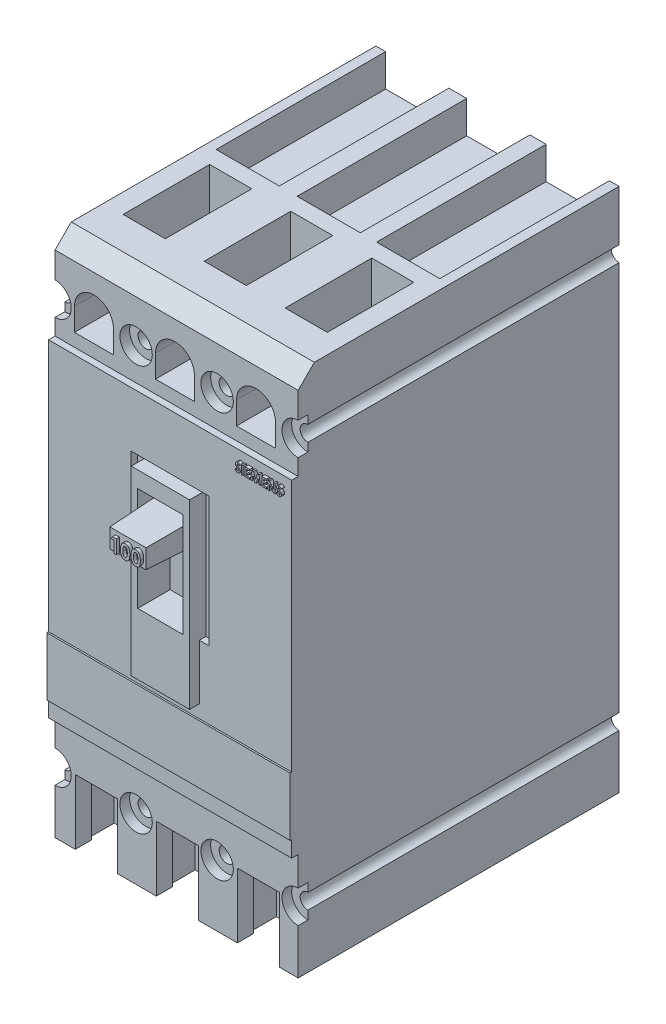
from build123d import *

# Parameters (mm, degrees)
CROQUIS1_W              = 75
CROQUIS1_H              = 162
SALIENTE_EXTRUIR1_DEPTH = 101
CROQUIS2_W              = 75
CROQUIS2_H              = 33
CROQUIS2_H_2            = 28
CORTAR_EXTRUIR1_DEPTH   = 2
CORTAR_EXTRUIR2_DEPTH   = 15
CROQUIS4_W              = 13
CROQUIS4_H              = 20
CORTAR_EXTRUIR3_DEPTH   = 5
CROQUIS5_R              = 5
CORTAR_EXTRUIR4_DEPTH   = 3
CROQUIS6_R              = 5
CORTAR_EXTRUIR5_DEPTH   = 3
CROQUIS7_R              = 2.38125
CROQUIS7_R_2            = 2.38
CORTAR_EXTRUIR6_DEPTH   = 96
CROQUIS8_R              = 5
CORTAR_EXTRUIR7_DEPTH   = 3
CROQUIS9_R              = 2.38
CORTAR_EXTRUIR8_DEPTH   = 96
CROQUIS10_W             = 13
CROQUIS10_H             = 26.695255465
CORTAR_EXTRUIR9_DEPTH   = 22
CROQUIS11_W             = 19.5
CROQUIS11_H             = 52.304744535
CORTAR_EXTRUIR10_DEPTH  = 10
CORTAR_EXTRUIR11_DEPTH  = 75
CORTAR_EXTRUIR12_DEPTH  = 20
CROQUIS14_W             = 12
CROQUIS14_H             = 13
CORTAR_EXTRUIR13_DEPTH  = 20
CORTAR_EXTRUIR14_DEPTH  = 10
CROQUIS16_W             = 24
CROQUIS16_H             = 40
CORTAR_EXTRUIR15_DEPTH  = 2
CROQUIS17_W             = 18
CROQUIS17_H             = 56
SALIENTE_EXTRUIR3_DEPTH = 5
CROQUIS18_W             = 14
CROQUIS18_H             = 32
CORTAR_EXTRUIR17_DEPTH  = 10
CROQUIS19_W             = 12.548186744
CROQUIS19_H             = 7.28259636
SALIENTE_EXTRUIR4_DEPTH = 20
SALIENTE_EXTRUIR4_TAPER = 2
SALIENTE_EXTRUIR5_DEPTH = 1
CROQUIS21_W             = 0.474893162
CROQUIS21_H             = 2.645833333
SALIENTE_EXTRUIR6_DEPTH = 1
CROQUIS22_W             = 75
CROQUIS22_H             = 18
SALIENTE_EXTRUIR7_DEPTH = 0.5


with BuildPart() as part:
    # Croquis1 → Saliente-Extruir1 (new body)
    with BuildSketch(Plane.XY):
        Rectangle(CROQUIS1_W, CROQUIS1_H)
    extrude(amount=SALIENTE_EXTRUIR1_DEPTH)

    # Croquis2 → Cortar-Extruir1 (cut)
    with BuildSketch(Plane.XY.offset(101)):
        with Locations((0, -64.5)):
            Rectangle(CROQUIS2_W, CROQUIS2_H)
        with Locations((0, 67)):
            Rectangle(CROQUIS2_W, CROQUIS2_H_2)
    extrude(amount=-CORTAR_EXTRUIR1_DEPTH, mode=Mode.SUBTRACT)

    # Croquis3 → Cortar-Extruir2 (cut)
    with BuildSketch(Plane.XY.offset(99)):
        with BuildLine():
            Line((-31.5, 57), (-19.5, 57))
            Line((-19.5, 57), (-19.5, 64))
            ThreePointArc((-19.5, 64), (-25.5, 70), (-31.5, 64))
            Line((-31.5, 64), (-31.5, 57))
        make_face()
        with BuildLine():
            Line((-6.5, 57), (-6.5, 64))
            ThreePointArc((-6.5, 64), (-0.5, 70), (5.5, 64))
            Line((5.5, 64), (5.5, 57))
            Line((5.5, 57), (-6.5, 57))
        make_face()
        with BuildLine():
            Line((18.5, 57), (18.5, 64))
            ThreePointArc((18.5, 64), (24.5, 70), (30.5, 64))
            Line((30.5, 64), (30.5, 57))
            Line((30.5, 57), (18.5, 57))
        make_face()
    extrude(amount=-CORTAR_EXTRUIR2_DEPTH, mode=Mode.SUBTRACT)

    # Croquis4 → Cortar-Extruir3 (cut)
    with BuildSketch(Plane.XY.offset(99)):
        with Locations((0.25, -71)):
            Rectangle(CROQUIS4_W, CROQUIS4_H)
        with Locations((-24.75, -71)):
            Rectangle(CROQUIS4_W, CROQUIS4_H)
        with Locations((25.25, -71)):
            Rectangle(CROQUIS4_W, CROQUIS4_H)
    extrude(amount=-CORTAR_EXTRUIR3_DEPTH, mode=Mode.SUBTRACT)

    # Croquis5 → Cortar-Extruir4 (cut)
    with BuildSketch(Plane.XY.offset(99)):
        with Locations((-12.5, 63)):
            Circle(CROQUIS5_R)
        with Locations((12.5, 63)):
            Circle(CROQUIS5_R)
    extrude(amount=-CORTAR_EXTRUIR4_DEPTH, mode=Mode.SUBTRACT)

    # Croquis6 → Cortar-Extruir5 (cut)
    with BuildSketch(Plane.XY.offset(99)):
        with Locations((-37.5, 63)):
            Circle(CROQUIS6_R)
        with Locations((37.5, 63)):
            Circle(CROQUIS6_R)
    extrude(amount=-CORTAR_EXTRUIR5_DEPTH, mode=Mode.SUBTRACT)

    # Croquis7 → Cortar-Extruir6 (cut)
    with BuildSketch(Plane.XY.offset(96)):
        with Locations((37.5, 63)):
            Circle(CROQUIS7_R)
        with Locations((12.5, 63)):
            Circle(CROQUIS7_R_2)
        with Locations((-37.5, 63)):
            Circle(CROQUIS7_R)
        with Locations((-12.5, 63)):
            Circle(CROQUIS7_R_2)
    extrude(amount=-CORTAR_EXTRUIR6_DEPTH, mode=Mode.SUBTRACT)

    # Croquis8 → Cortar-Extruir7 (cut)
    with BuildSketch(Plane.XY.offset(99)):
        with Locations((-12.5, -62)):
            Circle(CROQUIS8_R)
        with Locations((12.5, -62)):
            Circle(CROQUIS8_R)
        with Locations((37.5, -62)):
            Circle(CROQUIS8_R)
        with Locations((-37.5, -62)):
            Circle(CROQUIS8_R)
    extrude(amount=-CORTAR_EXTRUIR7_DEPTH, mode=Mode.SUBTRACT)

    # Croquis9 → Cortar-Extruir8 (cut)
    with BuildSketch(Plane.XY.offset(96)):
        with Locations((-37.5, -62)):
            Circle(CROQUIS9_R)
        with Locations((-12.5, -62)):
            Circle(CROQUIS9_R)
        with Locations((37.5, -62)):
            Circle(CROQUIS9_R)
        with Locations((12.5, -62)):
            Circle(CROQUIS9_R)
    extrude(amount=-CORTAR_EXTRUIR8_DEPTH, mode=Mode.SUBTRACT)

    # Croquis10 → Cortar-Extruir9 (cut)
    with BuildSketch(Plane(origin=(0, 81, 0), x_dir=(1, 0, 0), z_dir=(0, 1, 0))):
        with Locations((-25, -70.652372267)):
            Rectangle(CROQUIS10_W, CROQUIS10_H)
        with Locations((0, -70.652372267)):
            Rectangle(CROQUIS10_W, CROQUIS10_H)
        with Locations((25, -70.652372267)):
            Rectangle(CROQUIS10_W, CROQUIS10_H)
    extrude(amount=-CORTAR_EXTRUIR9_DEPTH, mode=Mode.SUBTRACT)

    # Croquis11 → Cortar-Extruir10 (cut)
    with BuildSketch(Plane(origin=(0, 81, 0), x_dir=(1, 0, 0), z_dir=(0, 1, 0))):
        with Locations((-24.75, -26.152372268)):
            Rectangle(CROQUIS11_W, CROQUIS11_H)
        with Locations((0.25, -26.152372268)):
            Rectangle(CROQUIS11_W, CROQUIS11_H)
        with Locations((24.75, -26.152372268)):
            Rectangle(CROQUIS11_W, CROQUIS11_H)
    extrude(amount=-CORTAR_EXTRUIR10_DEPTH, mode=Mode.SUBTRACT)

    # Croquis12 → Cortar-Extruir11 (cut)
    with BuildSketch(Plane.ZY.offset(37.5)):
        Polygon((99, 81), (94, 81), (99, 76), align=None)
    extrude(amount=-CORTAR_EXTRUIR11_DEPTH, mode=Mode.SUBTRACT)

    # Croquis13 → Cortar-Extruir12 (cut)
    with BuildSketch(Plane.XZ.offset(81)):
        Polygon((-18.25, 94), (-17.25, 94), (-17.25, 86), (-32.25, 86), (-32.25, 94), (-31.25, 94), align=None)
        Polygon((-6.25, 94), (-7.25, 94), (-7.25, 86), (7.75, 86), (7.75, 94), (6.75, 94), align=None)
        Polygon((18.75, 94), (17.75, 94), (17.75, 86), (32.75, 86), (32.75, 94), (31.75, 94), align=None)
    extrude(amount=-CORTAR_EXTRUIR12_DEPTH, mode=Mode.SUBTRACT)

    # Croquis14 → Cortar-Extruir13 (cut)
    with BuildSketch(Plane.XZ.offset(81)):
        with Locations((-24.5, 70.5)):
            Rectangle(CROQUIS14_W, CROQUIS14_H)
        with Locations((0, 70.5)):
            Rectangle(CROQUIS14_W, CROQUIS14_H)
        with Locations((24, 70.5)):
            Rectangle(CROQUIS14_W, CROQUIS14_H)
    extrude(amount=-CORTAR_EXTRUIR13_DEPTH, mode=Mode.SUBTRACT)

    # Croquis15 → Cortar-Extruir14 (cut)
    with BuildSketch(Plane.XZ.offset(81)):
        Polygon((-34.5, 59), (-15, 59), (-15, 28.610337505), (-16.610337505, 27), (-32.997400016, 27), (-34.5, 28.993221884), align=None)
        Polygon((-10, 59), (-10, 28.610337505), (-8.389662495, 27), (7.889662495, 27), (9.5, 28.610337505), (9.5, 59), align=None)
        Polygon((14.5, 59), (14.5, 28.610337505), (16.110337505, 27), (31.889662495, 27), (33.5, 28.610337505), (33.5, 59), align=None)
    extrude(amount=-CORTAR_EXTRUIR14_DEPTH, mode=Mode.SUBTRACT)

    # Croquis16 → Cortar-Extruir15 (cut)
    with BuildSketch(Plane.XY.offset(101)):
        with Locations((0, 16)):
            Rectangle(CROQUIS16_W, CROQUIS16_H)
    extrude(amount=-CORTAR_EXTRUIR15_DEPTH, mode=Mode.SUBTRACT)

    # Croquis17 → Saliente-Extruir3 (add)
    with BuildSketch(Plane.XY.offset(99)):
        with Locations((0, 7)):
            Rectangle(CROQUIS17_W, CROQUIS17_H)
    extrude(amount=SALIENTE_EXTRUIR3_DEPTH)

    # Croquis18 → Cortar-Extruir17 (cut)
    with BuildSketch(Plane.XY.offset(104)):
        with Locations((0, 14)):
            Rectangle(CROQUIS18_W, CROQUIS18_H)
    extrude(amount=-CORTAR_EXTRUIR17_DEPTH, mode=Mode.SUBTRACT)

    # Croquis19 → Saliente-Extruir4 (add)
    with BuildSketch(Plane.XY.offset(94)):
        with Locations((0, 22.535796571)):
            Rectangle(CROQUIS19_W, CROQUIS19_H)
    extrude(amount=SALIENTE_EXTRUIR4_DEPTH, taper=SALIENTE_EXTRUIR4_TAPER)

    # Croquis20 → Saliente-Extruir5 (add)
    with BuildSketch(Plane.XY.offset(114)):
        Polygon((-3.791447344, 24.246694627), (-2.616934791, 24.246694627), (-2.616934791, 20.013361294), (-3.376763851, 20.013361294), (-3.376763851, 23.541139072), (-4.245139919, 23.541139072), align=None)
        with BuildLine():
            add(Edge.make_bspline(
                [(0.111156822, 24.355241636), (0.147935703, 24.354695643), (0.220252808, 24.353622075), (0.326762291, 24.341994461), (0.429360371, 24.32442838), (0.528448425, 24.299929821), (0.623313206, 24.267506852), (0.714645161, 24.228697113), (0.801357174, 24.181464955), (0.884555101, 24.128113806), (0.964206895, 24.067712742), (1.038398179, 23.99885241), (1.108483844, 23.92311729), (1.172946794, 23.839362403), (1.23321458, 23.748349587), (1.289089173, 23.650064411), (1.340142839, 23.544025835), (1.386947768, 23.430042504), (1.428800882, 23.306405858), (1.464053709, 23.171697729), (1.494288907, 23.025887355), (1.519809547, 22.868611793), (1.539099026, 22.699661984), (1.552100523, 22.519150172), (1.561022766, 22.327424356), (1.561750937, 22.195902022), (1.562125038, 22.128331914)],
                knots=[0, 0, 0, 0, 0.000110295, 0.00021687, 0.000321015, 0.000422413, 0.000522709, 0.000621478, 0.00071975, 0.000818547, 0.00091777, 0.001019196, 0.001121821, 0.00122699, 0.001335887, 0.001449066, 0.001565884, 0.001688719, 0.001818513, 0.001957154, 0.002106175, 0.002265108, 0.002434989, 0.002616126, 0.002807967, 0.003010661, 0.003010661, 0.003010661, 0.003010661], degree=3))
            add(Edge.make_bspline(
                [(1.562125038, 22.128331914), (1.561720736, 22.059916428), (1.560935185, 21.926986366), (1.552471424, 21.733506928), (1.537896426, 21.551684492), (1.519111118, 21.381537867), (1.493380384, 21.223156907), (1.463246118, 21.07613151), (1.427436836, 20.94051497), (1.384205094, 20.816612859), (1.337683476, 20.702429349), (1.286490157, 20.596597523), (1.231517427, 20.498830731), (1.174026196, 20.407654027), (1.110864583, 20.325755255), (1.045106842, 20.250349427), (0.973889762, 20.18430885), (0.900211859, 20.124230087), (0.821374013, 20.072309979), (0.738189258, 20.026901509), (0.649174554, 19.990069846), (0.555952487, 19.958035633), (0.45693407, 19.935038525), (0.35369269, 19.916791075), (0.245062774, 19.906706415), (0.171103151, 19.905455347), (0.133205434, 19.904814285)],
                knots=[0, 0, 0, 0, 0.000205237, 0.000398773, 0.000580821, 0.000752386, 0.000912157, 0.001062008, 0.001202506, 0.001332575, 0.00145541, 0.001572228, 0.00168499, 0.001791787, 0.001895249, 0.00199497, 0.002091559, 0.002186254, 0.002279863, 0.002374345, 0.002470107, 0.002568526, 0.002669722, 0.002774702, 0.002882881, 0.002996566, 0.002996566, 0.002996566, 0.002996566], degree=3))
            add(Edge.make_bspline(
                [(0.133205434, 19.904814285), (0.095308739, 19.905467712), (0.021069671, 19.906747766), (-0.087853991, 19.916716091), (-0.191642498, 19.935112445), (-0.291444311, 19.958212188), (-0.386564823, 19.989998967), (-0.477460136, 20.027932607), (-0.563431343, 20.073057751), (-0.644716485, 20.125098828), (-0.721038031, 20.184775618), (-0.793582017, 20.251449812), (-0.862187972, 20.324952408), (-0.92581223, 20.406106696), (-0.985496771, 20.493829434), (-1.04061918, 20.589122375), (-1.09114633, 20.691846773), (-1.13865872, 20.802145817), (-1.179940972, 20.922394117), (-1.21668026, 21.053665477), (-1.246776119, 21.19705415), (-1.270981222, 21.352514073), (-1.290306562, 21.519715896), (-1.304682394, 21.698740322), (-1.313193168, 21.889670738), (-1.313970481, 22.020906724), (-1.314370688, 22.088474809)],
                knots=[0, 0, 0, 0, 0.000113686, 0.000222709, 0.000327689, 0.00042971, 0.000529737, 0.000628173, 0.0007249, 0.00082064, 0.00091733, 0.001015162, 0.001115966, 0.001218608, 0.001324217, 0.001434032, 0.001548566, 0.001667489, 0.001794074, 0.001929665, 0.002076197, 0.002233322, 0.002401517, 0.00258103, 0.002772023, 0.002974717, 0.002974717, 0.002974717, 0.002974717], degree=3))
            add(Edge.make_bspline(
                [(-1.314370688, 22.088474809), (-1.313645751, 22.182355344), (-1.312246974, 22.363499046), (-1.294520652, 22.625199028), (-1.268502908, 22.867095328), (-1.230289005, 23.088783314), (-1.183038041, 23.291084052), (-1.122530723, 23.472664893), (-1.053647542, 23.636038413), (-0.994950222, 23.73282187), (-0.966681051, 23.779433676)],
                knots=[0, 0, 0, 0, 0.00028159, 0.000543331, 0.000786536, 0.001011136, 0.001217849, 0.001409053, 0.001584881, 0.001748233, 0.001748233, 0.001748233, 0.001748233], degree=3))
            add(Edge.make_bspline(
                [(-0.966681051, 23.779433676), (-0.933811006, 23.825225101), (-0.86954359, 23.914756358), (-0.757170216, 24.032294163), (-0.636439657, 24.13281825), (-0.504872176, 24.214053668), (-0.364548567, 24.278115925), (-0.21426408, 24.323362376), (-0.054573692, 24.349725067), (0.055088362, 24.35337532), (0.111156822, 24.355241636)],
                knots=[0, 0, 0, 0, 0.000168927, 0.000330286, 0.000486315, 0.000639039, 0.00079274, 0.000947801, 0.001108545, 0.001276713, 0.001276713, 0.001276713, 0.001276713], degree=3))
        make_face()
        with BuildLine():
            add(Edge.make_bspline(
                [(0.12981334, 23.595412576), (0.096564927, 23.593836667), (0.031380389, 23.59074705), (-0.063205482, 23.564520556), (-0.152394052, 23.524012323), (-0.220237415, 23.475266997), (-0.271017498, 23.428538757), (-0.306497906, 23.386251219), (-0.340713167, 23.339061375), (-0.370933809, 23.284839789), (-0.399469984, 23.225534707), (-0.427358428, 23.160876919), (-0.450219629, 23.08927829), (-0.472680153, 23.011958155), (-0.492357668, 22.926778816), (-0.508843111, 22.833044027), (-0.523571406, 22.730144222), (-0.533844567, 22.618012001), (-0.543422236, 22.496764682), (-0.550287963, 22.366132174), (-0.553158351, 22.226149717), (-0.55407076, 22.129745877), (-0.554541628, 22.079994574)],
                knots=[0, 0, 0, 0, 9.958e-05, 0.000195231, 0.000292365, 0.00039213, 0.00044433, 0.000499059, 0.000557418, 0.000618951, 0.000684945, 0.000754874, 0.000829962, 0.00091022, 0.00099641, 0.001092056, 0.001195675, 0.001308156, 0.001429781, 0.001560553, 0.001700518, 0.00184978, 0.00184978, 0.00184978, 0.00184978], degree=3))
            add(Edge.make_bspline(
                [(-0.554541628, 22.079994574), (-0.553766636, 22.015539356), (-0.55228053, 21.891941697), (-0.544497004, 21.71420396), (-0.528895571, 21.552448307), (-0.509490538, 21.405578461), (-0.482235377, 21.274546912), (-0.45087655, 21.158113979), (-0.412151187, 21.0577639), (-0.367396569, 20.972045388), (-0.317828812, 20.899124828), (-0.264020832, 20.837142023), (-0.207804597, 20.783467838), (-0.147425416, 20.739868959), (-0.083027335, 20.706456788), (-0.01514796, 20.682423827), (0.056255845, 20.66771225), (0.105152435, 20.665672227), (0.12981334, 20.664643345)],
                knots=[0, 0, 0, 0, 0.000193379, 0.000370819, 0.000533509, 0.000680782, 0.000814998, 0.000934746, 0.001042148, 0.001136979, 0.001224243, 0.001306014, 0.001382806, 0.001456939, 0.001528626, 0.001599703, 0.001672381, 0.001746335, 0.001746335, 0.001746335, 0.001746335], degree=3))
            add(Edge.make_bspline(
                [(0.12981334, 20.664643345), (0.15362796, 20.665347383), (0.200254027, 20.6667258), (0.268245273, 20.680875071), (0.332542628, 20.703878711), (0.392951955, 20.736418976), (0.449689333, 20.777798901), (0.502477462, 20.828200328), (0.550918226, 20.888125641), (0.579140035, 20.932599086), (0.593682196, 20.955515407)],
                knots=[0, 0, 0, 0, 7.136e-05, 0.000139714, 0.000207312, 0.000275603, 0.000344809, 0.000417388, 0.000493941, 0.00057532, 0.00057532, 0.00057532, 0.00057532], degree=3))
            add(Edge.make_bspline(
                [(0.593682196, 20.955515407), (0.610803143, 20.986829828), (0.646704379, 21.052493627), (0.688249351, 21.163298841), (0.723219593, 21.288268809), (0.753317969, 21.427792449), (0.773903423, 21.58242006), (0.79163159, 21.751171134), (0.800182325, 21.934895434), (0.801573149, 22.062180291), (0.802295978, 22.128331914)],
                knots=[0, 0, 0, 0, 0.000106959, 0.000224283, 0.000353931, 0.000496139, 0.000652046, 0.000821653, 0.001005064, 0.00120353, 0.00120353, 0.00120353, 0.00120353], degree=3))
            add(Edge.make_bspline(
                [(0.802295978, 22.128331914), (0.802016765, 22.195057764), (0.801479327, 22.323493635), (0.791618893, 22.507878437), (0.777887486, 22.676283352), (0.757802402, 22.8283324), (0.73195929, 22.964394691), (0.700107557, 23.084461329), (0.662556733, 23.188768943), (0.618025931, 23.277213524), (0.568705301, 23.352379285), (0.516349946, 23.416865677), (0.460738488, 23.471922533), (0.401963926, 23.517757039), (0.338665902, 23.552778039), (0.272053492, 23.577505762), (0.201990134, 23.592465206), (0.154197006, 23.594416859), (0.12981334, 23.595412576)],
                knots=[0, 0, 0, 0, 0.00020015, 0.000385254, 0.00055378, 0.000706935, 0.000845142, 0.00096898, 0.001079252, 0.001177099, 0.001265301, 0.001348477, 0.001425833, 0.001499616, 0.001571358, 0.001641928, 0.001712114, 0.001785221, 0.001785221, 0.001785221, 0.001785221], degree=3))
        make_face(mode=Mode.SUBTRACT)
        with BuildLine():
            add(Edge.make_bspline(
                [(3.367567079, 24.355241636), (3.404345959, 24.354695643), (3.476663064, 24.353622075), (3.583172547, 24.341994461), (3.685770627, 24.32442838), (3.784858681, 24.299929821), (3.879723463, 24.267506852), (3.971055417, 24.228697113), (4.057767431, 24.181464955), (4.140965358, 24.128113806), (4.220617151, 24.067712742), (4.294808435, 23.99885241), (4.3648941, 23.92311729), (4.42935705, 23.839362403), (4.489624837, 23.748349587), (4.54549943, 23.650064411), (4.596553096, 23.544025835), (4.643358024, 23.430042504), (4.685211139, 23.306405858), (4.720463965, 23.171697729), (4.750699163, 23.025887355), (4.776219803, 22.868611793), (4.795509282, 22.699661984), (4.80851078, 22.519150172), (4.817433023, 22.327424356), (4.818161194, 22.195902022), (4.818535295, 22.128331914)],
                knots=[0, 0, 0, 0, 0.000110295, 0.00021687, 0.000321015, 0.000422413, 0.000522709, 0.000621478, 0.00071975, 0.000818547, 0.00091777, 0.001019196, 0.001121821, 0.00122699, 0.001335887, 0.001449066, 0.001565884, 0.001688719, 0.001818513, 0.001957154, 0.002106175, 0.002265108, 0.002434989, 0.002616126, 0.002807967, 0.003010661, 0.003010661, 0.003010661, 0.003010661], degree=3))
            add(Edge.make_bspline(
                [(4.818535295, 22.128331914), (4.818130993, 22.059916428), (4.817345442, 21.926986366), (4.80888168, 21.733506928), (4.794306683, 21.551684492), (4.775521375, 21.381537867), (4.749790641, 21.223156907), (4.719656375, 21.07613151), (4.683847093, 20.94051497), (4.64061535, 20.816612859), (4.594093733, 20.702429349), (4.542900413, 20.596597523), (4.487927684, 20.498830731), (4.430436453, 20.407654027), (4.36727484, 20.325755255), (4.301517098, 20.250349427), (4.230300019, 20.18430885), (4.156622116, 20.124230087), (4.077784269, 20.072309979), (3.994599514, 20.026901509), (3.90558481, 19.990069846), (3.812362744, 19.958035633), (3.713344326, 19.935038525), (3.610102946, 19.916791075), (3.50147303, 19.906706415), (3.427513408, 19.905455347), (3.38961569, 19.904814285)],
                knots=[0, 0, 0, 0, 0.000205237, 0.000398773, 0.000580821, 0.000752386, 0.000912157, 0.001062008, 0.001202506, 0.001332575, 0.00145541, 0.001572228, 0.00168499, 0.001791787, 0.001895249, 0.00199497, 0.002091559, 0.002186254, 0.002279863, 0.002374345, 0.002470107, 0.002568526, 0.002669722, 0.002774702, 0.002882881, 0.002996566, 0.002996566, 0.002996566, 0.002996566], degree=3))
            add(Edge.make_bspline(
                [(3.38961569, 19.904814285), (3.351718995, 19.905467712), (3.277479928, 19.906747766), (3.168556265, 19.916716091), (3.064767758, 19.935112445), (2.964965946, 19.958212188), (2.869845433, 19.989998967), (2.77895012, 20.027932607), (2.692978913, 20.073057751), (2.611693771, 20.125098828), (2.535372226, 20.184775618), (2.462828239, 20.251449812), (2.394222284, 20.324952408), (2.330598027, 20.406106696), (2.270913486, 20.493829434), (2.215791076, 20.589122375), (2.165263926, 20.691846773), (2.117751537, 20.802145817), (2.076469284, 20.922394117), (2.039729996, 21.053665477), (2.009634138, 21.19705415), (1.985429035, 21.352514073), (1.966103694, 21.519715896), (1.951727862, 21.698740322), (1.943217088, 21.889670738), (1.942439775, 22.020906724), (1.942039568, 22.088474809)],
                knots=[0, 0, 0, 0, 0.000113686, 0.000222709, 0.000327689, 0.00042971, 0.000529737, 0.000628173, 0.0007249, 0.00082064, 0.00091733, 0.001015162, 0.001115966, 0.001218608, 0.001324217, 0.001434032, 0.001548566, 0.001667489, 0.001794074, 0.001929665, 0.002076197, 0.002233322, 0.002401517, 0.00258103, 0.002772023, 0.002974717, 0.002974717, 0.002974717, 0.002974717], degree=3))
            add(Edge.make_bspline(
                [(1.942039568, 22.088474809), (1.942764506, 22.182355344), (1.944163282, 22.363499046), (1.961889604, 22.625199028), (1.987907348, 22.867095328), (2.026121252, 23.088783314), (2.073372215, 23.291084052), (2.133879534, 23.472664893), (2.202762714, 23.636038413), (2.261460034, 23.73282187), (2.289729205, 23.779433676)],
                knots=[0, 0, 0, 0, 0.00028159, 0.000543331, 0.000786536, 0.001011136, 0.001217849, 0.001409053, 0.001584881, 0.001748233, 0.001748233, 0.001748233, 0.001748233], degree=3))
            add(Edge.make_bspline(
                [(2.289729205, 23.779433676), (2.322599251, 23.825225101), (2.386866667, 23.914756358), (2.49924004, 24.032294163), (2.619970599, 24.13281825), (2.75153808, 24.214053668), (2.89186169, 24.278115925), (3.042146176, 24.323362376), (3.201836565, 24.349725067), (3.311498618, 24.35337532), (3.367567079, 24.355241636)],
                knots=[0, 0, 0, 0, 0.000168927, 0.000330286, 0.000486315, 0.000639039, 0.00079274, 0.000947801, 0.001108545, 0.001276713, 0.001276713, 0.001276713, 0.001276713], degree=3))
        make_face()
        with BuildLine():
            add(Edge.make_bspline(
                [(3.386223596, 23.595412576), (3.352975183, 23.593836667), (3.287790645, 23.59074705), (3.193204775, 23.564520556), (3.104016204, 23.524012323), (3.036172841, 23.475266997), (2.985392758, 23.428538757), (2.94991235, 23.386251219), (2.915697089, 23.339061375), (2.885476447, 23.284839789), (2.856940273, 23.225534707), (2.829051828, 23.160876919), (2.806190627, 23.08927829), (2.783730104, 23.011958155), (2.764052589, 22.926778816), (2.747567145, 22.833044027), (2.732838851, 22.730144222), (2.72256569, 22.618012001), (2.71298802, 22.496764682), (2.706122294, 22.366132174), (2.703251906, 22.226149717), (2.702339497, 22.129745877), (2.701868628, 22.079994574)],
                knots=[0, 0, 0, 0, 9.958e-05, 0.000195231, 0.000292365, 0.00039213, 0.00044433, 0.000499059, 0.000557418, 0.000618951, 0.000684945, 0.000754874, 0.000829962, 0.00091022, 0.00099641, 0.001092056, 0.001195675, 0.001308156, 0.001429781, 0.001560553, 0.001700518, 0.00184978, 0.00184978, 0.00184978, 0.00184978], degree=3))
            add(Edge.make_bspline(
                [(2.701868628, 22.079994574), (2.702643621, 22.015539356), (2.704129726, 21.891941697), (2.711913253, 21.71420396), (2.727514686, 21.552448307), (2.746919719, 21.405578461), (2.774174879, 21.274546912), (2.805533706, 21.158113979), (2.844259069, 21.0577639), (2.889013688, 20.972045388), (2.938581444, 20.899124828), (2.992389424, 20.837142023), (3.048605659, 20.783467838), (3.10898484, 20.739868959), (3.173382921, 20.706456788), (3.241262296, 20.682423827), (3.312666101, 20.66771225), (3.361562691, 20.665672227), (3.386223596, 20.664643345)],
                knots=[0, 0, 0, 0, 0.000193379, 0.000370819, 0.000533509, 0.000680782, 0.000814998, 0.000934746, 0.001042148, 0.001136979, 0.001224243, 0.001306014, 0.001382806, 0.001456939, 0.001528626, 0.001599703, 0.001672381, 0.001746335, 0.001746335, 0.001746335, 0.001746335], degree=3))
            add(Edge.make_bspline(
                [(3.386223596, 20.664643345), (3.410038217, 20.665347383), (3.456664283, 20.6667258), (3.52465553, 20.680875071), (3.588952884, 20.703878711), (3.649362212, 20.736418976), (3.706099589, 20.777798901), (3.758887718, 20.828200328), (3.807328482, 20.888125641), (3.835550291, 20.932599086), (3.850092453, 20.955515407)],
                knots=[0, 0, 0, 0, 7.136e-05, 0.000139714, 0.000207312, 0.000275603, 0.000344809, 0.000417388, 0.000493941, 0.00057532, 0.00057532, 0.00057532, 0.00057532], degree=3))
            add(Edge.make_bspline(
                [(3.850092453, 20.955515407), (3.867213399, 20.986829828), (3.903114635, 21.052493627), (3.944659608, 21.163298841), (3.97962985, 21.288268809), (4.009728226, 21.427792449), (4.030313679, 21.58242006), (4.048041846, 21.751171134), (4.056592582, 21.934895434), (4.057983405, 22.062180291), (4.058706235, 22.128331914)],
                knots=[0, 0, 0, 0, 0.000106959, 0.000224283, 0.000353931, 0.000496139, 0.000652046, 0.000821653, 0.001005064, 0.00120353, 0.00120353, 0.00120353, 0.00120353], degree=3))
            add(Edge.make_bspline(
                [(4.058706235, 22.128331914), (4.058427021, 22.195057764), (4.057889583, 22.323493635), (4.04802915, 22.507878437), (4.034297743, 22.676283352), (4.014212658, 22.8283324), (3.988369546, 22.964394691), (3.956517813, 23.084461329), (3.918966989, 23.188768943), (3.874436187, 23.277213524), (3.825115557, 23.352379285), (3.772760203, 23.416865677), (3.717148744, 23.471922533), (3.658374182, 23.517757039), (3.595076159, 23.552778039), (3.528463748, 23.577505762), (3.458400391, 23.592465206), (3.410607262, 23.594416859), (3.386223596, 23.595412576)],
                knots=[0, 0, 0, 0, 0.00020015, 0.000385254, 0.00055378, 0.000706935, 0.000845142, 0.00096898, 0.001079252, 0.001177099, 0.001265301, 0.001348477, 0.001425833, 0.001499616, 0.001571358, 0.001641928, 0.001712114, 0.001785221, 0.001785221, 0.001785221, 0.001785221], degree=3))
        make_face(mode=Mode.SUBTRACT)
    extrude(amount=SALIENTE_EXTRUIR5_DEPTH)

    # Croquis21 → Saliente-Extruir6 (add)
    with BuildSketch(Plane.XY.offset(101)):
        with BuildLine():
            Line((22.56777865, 50.042662848), (22.212668808, 49.717763842))
            add(Edge.make_bspline(
                [(22.212668808, 49.717763842), (22.197457425, 49.73922108), (22.168253691, 49.780415982), (22.120917484, 49.835576928), (22.073795025, 49.88263332), (22.026449751, 49.921388578), (21.978462014, 49.951607235), (21.929915112, 49.973002378), (21.881084272, 49.986603474), (21.848277485, 49.988297137), (21.83211826, 49.989131364)],
                knots=[0, 0, 0, 0, 7.8871e-05, 0.000151421, 0.000217757, 0.000278432, 0.000334614, 0.000387299, 0.000437179, 0.000485597, 0.000485597, 0.000485597, 0.000485597], degree=3))
            add(Edge.make_bspline(
                [(21.83211826, 49.989131364), (21.817045399, 49.98860276), (21.787943665, 49.987582164), (21.746456984, 49.977437518), (21.709624518, 49.959929349), (21.677482213, 49.937035946), (21.652020765, 49.909454702), (21.631691774, 49.880529069), (21.620244844, 49.848601711), (21.618738202, 49.826672714), (21.617992325, 49.81581656)],
                knots=[0, 0, 0, 0, 4.5163e-05, 8.7199e-05, 0.000127031, 0.000166895, 0.000204764, 0.000239162, 0.000272355, 0.000304898, 0.000304898, 0.000304898, 0.000304898], degree=3))
            add(Edge.make_bspline(
                [(21.617992325, 49.81581656), (21.618459729, 49.804803855), (21.619401014, 49.782625798), (21.628492546, 49.750121093), (21.642196081, 49.718360213), (21.655290368, 49.699025853), (21.661983545, 49.689143049)],
                knots=[0, 0, 0, 0, 3.2968e-05, 6.6392e-05, 0.000100565, 0.000136297, 0.000136297, 0.000136297, 0.000136297], degree=3))
            add(Edge.make_bspline(
                [(21.661983545, 49.689143049), (21.668068366, 49.681461249), (21.682074822, 49.663778759), (21.708782263, 49.635772451), (21.742321201, 49.601462273), (21.783982284, 49.56202805), (21.832036045, 49.516051575), (21.88870984, 49.465340199), (21.952372348, 49.40832345), (21.997622184, 49.368619051), (22.021333505, 49.347813589)],
                knots=[0, 0, 0, 0, 2.9386e-05, 6.7643e-05, 0.00011599, 0.000173342, 0.000239704, 0.000315502, 0.000401464, 0.000496098, 0.000496098, 0.000496098, 0.000496098], degree=3))
            add(Edge.make_bspline(
                [(22.021333505, 49.347813589), (22.04358999, 49.328551723), (22.085828177, 49.291996703), (22.145924728, 49.240112722), (22.198739587, 49.19343397), (22.245042147, 49.152660994), (22.284130505, 49.117365993), (22.31616899, 49.087380256), (22.341548896, 49.063287552), (22.355975887, 49.048735544), (22.36213295, 49.042525127)],
                knots=[0, 0, 0, 0, 8.8303e-05, 0.00016758, 0.000238182, 0.000299759, 0.000352668, 0.000396168, 0.000431405, 0.000457639, 0.000457639, 0.000457639, 0.000457639], degree=3))
            add(Edge.make_bspline(
                [(22.36213295, 49.042525127), (22.385491565, 49.017246104), (22.430395025, 48.968650943), (22.488753694, 48.893343726), (22.536784766, 48.819828528), (22.573942514, 48.746722039), (22.60200554, 48.672969479), (22.621790345, 48.596762071), (22.633639596, 48.517303495), (22.63495514, 48.463082716), (22.635620531, 48.435658307)],
                knots=[0, 0, 0, 0, 0.000103217, 0.000198419, 0.000285453, 0.000366281, 0.000443948, 0.000521723, 0.000602076, 0.000684312, 0.000684312, 0.000684312, 0.000684312], degree=3))
            add(Edge.make_bspline(
                [(22.635620531, 48.435658307), (22.635146923, 48.408936584), (22.634217686, 48.356507568), (22.622836318, 48.279785513), (22.606607156, 48.206359177), (22.581514023, 48.137027541), (22.550930662, 48.070652549), (22.512590002, 48.008268111), (22.467564154, 47.949242872), (22.415957619, 47.89463198), (22.358874663, 47.845076381), (22.297647767, 47.800960816), (22.231678225, 47.764537798), (22.161529669, 47.73454604), (22.087239649, 47.711445988), (22.008896666, 47.694372896), (21.92638089, 47.684125895), (21.869955413, 47.683054693), (21.84112851, 47.682507432)],
                knots=[0, 0, 0, 0, 8.0095e-05, 0.00015715, 0.000232233, 0.000305321, 0.000377877, 0.000451142, 0.000524499, 0.000600237, 0.000676123, 0.000750983, 0.000826195, 0.000901705, 0.000979485, 0.001059222, 0.001141989, 0.00122844, 0.00122844, 0.00122844, 0.00122844], degree=3))
            add(Edge.make_bspline(
                [(21.84112851, 47.682507432), (21.818499637, 47.682908883), (21.77368149, 47.683703987), (21.707626316, 47.690195348), (21.64384258, 47.700671713), (21.582402126, 47.715687474), (21.523028155, 47.73471448), (21.465718229, 47.757955239), (21.410867977, 47.785769974), (21.358062375, 47.817586703), (21.307558126, 47.854530117), (21.258716621, 47.895844919), (21.212023001, 47.94216655), (21.167253006, 47.99338546), (21.124693088, 48.04964669), (21.082950106, 48.110166697), (21.043879246, 48.176068651), (21.019743438, 48.222299405), (21.007415402, 48.245913048)],
                knots=[0, 0, 0, 0, 6.7875e-05, 0.000134431, 0.00019891, 0.000261643, 0.000323996, 0.000385805, 0.00044696, 0.000508315, 0.000570547, 0.000634474, 0.000700061, 0.000767671, 0.000838378, 0.000911589, 0.000988124, 0.001068032, 0.001068032, 0.001068032, 0.001068032], degree=3))
            Line((21.007415402, 48.245913048), (21.425066978, 48.496609996))
            add(Edge.make_bspline(
                [(21.425066978, 48.496609996), (21.440487508, 48.469805426), (21.470049981, 48.418418775), (21.520146355, 48.349374296), (21.571467532, 48.290249128), (21.625200014, 48.242088314), (21.680690431, 48.20424788), (21.738206817, 48.177204481), (21.79778958, 48.160464648), (21.838374652, 48.158420327), (21.858618995, 48.157400595)],
                knots=[0, 0, 0, 0, 9.2715e-05, 0.000177742, 0.000255474, 0.000327175, 0.000393619, 0.000456217, 0.00051716, 0.000577813, 0.000577813, 0.000577813, 0.000577813], degree=3))
            add(Edge.make_bspline(
                [(21.858618995, 48.157400595), (21.87921039, 48.158233364), (21.919160696, 48.159849057), (21.976184645, 48.174772726), (22.02846636, 48.198203982), (22.073658289, 48.231637153), (22.111923965, 48.270224114), (22.14016623, 48.313153873), (22.157908212, 48.359602835), (22.15978397, 48.39186934), (22.160727368, 48.408097543)],
                knots=[0, 0, 0, 0, 6.1666e-05, 0.000119642, 0.000175613, 0.000232545, 0.000287267, 0.000337839, 0.000385792, 0.000434314, 0.000434314, 0.000434314, 0.000434314], degree=3))
            add(Edge.make_bspline(
                [(22.160727368, 48.408097543), (22.159856178, 48.423195245), (22.158086439, 48.453864781), (22.145051087, 48.49946545), (22.124672855, 48.545045381), (22.10056397, 48.582431273), (22.07603016, 48.613733467), (22.052570304, 48.640855402), (22.024002406, 48.670820392), (21.990398901, 48.703666131), (21.952203778, 48.739681768), (21.909384865, 48.778863776), (21.861451837, 48.820867009), (21.827572679, 48.849479196), (21.809857643, 48.864440191)],
                knots=[0, 0, 0, 0, 4.525e-05, 9.1922e-05, 0.00014127, 0.000194644, 0.000224859, 0.00026056, 0.000302175, 0.000349024, 0.000401514, 0.000459664, 0.000523135, 0.000592696, 0.000592696, 0.000592696, 0.000592696], degree=3))
            add(Edge.make_bspline(
                [(21.809857643, 48.864440191), (21.776180655, 48.892934152), (21.711544322, 48.947622688), (21.620204983, 49.028395934), (21.53790006, 49.103885934), (21.465340427, 49.175025908), (21.401601562, 49.240502067), (21.347115131, 49.300846233), (21.302479695, 49.356523879), (21.255510522, 49.422470324), (21.210880418, 49.502830599), (21.172307342, 49.599513326), (21.147282759, 49.696183785), (21.144479102, 49.761083007), (21.143099163, 49.793025928)],
                knots=[0, 0, 0, 0, 0.000132338, 0.000253997, 0.000365771, 0.000467342, 0.0005588, 0.000639876, 0.000711145, 0.000772759, 0.000882617, 0.000985861, 0.001084587, 0.001180278, 0.001180278, 0.001180278, 0.001180278], degree=3))
            add(Edge.make_bspline(
                [(21.143099163, 49.793025928), (21.143673078, 49.815678134), (21.144803752, 49.860305412), (21.154889538, 49.925923323), (21.16996313, 49.989239093), (21.191854312, 50.050021718), (21.220266424, 50.108195065), (21.25477183, 50.164043918), (21.295906334, 50.217054255), (21.342262143, 50.267190936), (21.393334376, 50.313010156), (21.447911547, 50.353450209), (21.505684745, 50.387606466), (21.566300543, 50.415941561), (21.630134551, 50.437630277), (21.696716507, 50.453004319), (21.766141911, 50.46214831), (21.813363572, 50.463391329), (21.837418407, 50.464024526)],
                knots=[0, 0, 0, 0, 6.7916e-05, 0.000133803, 0.00019872, 0.000262931, 0.00032717, 0.000392622, 0.000459515, 0.000528149, 0.00059721, 0.000665054, 0.000731591, 0.000798224, 0.000865435, 0.000933447, 0.001002935, 0.001075087, 0.001075087, 0.001075087, 0.001075087], degree=3))
            add(Edge.make_bspline(
                [(21.837418407, 50.464024526), (21.868592283, 50.462884119), (21.930693958, 50.460612308), (22.022513076, 50.442847483), (22.112198152, 50.414910426), (22.184468067, 50.38120744), (22.241971889, 50.348559341), (22.286043198, 50.318501084), (22.330888126, 50.284067736), (22.376868321, 50.245150787), (22.423129399, 50.201016991), (22.470986784, 50.152716987), (22.519788362, 50.099833352), (22.551501649, 50.062053529), (22.56777865, 50.042662848)],
                knots=[0, 0, 0, 0, 9.3465e-05, 0.000186191, 0.00027956, 0.000374659, 0.000424753, 0.00047782, 0.000534534, 0.000594323, 0.000658437, 0.000726273, 0.000798292, 0.000874234, 0.000874234, 0.000874234, 0.000874234], degree=3))
        make_face()
        with Locations((23.280118394, 49.07326598)):
            Rectangle(CROQUIS21_W, CROQUIS21_H)
        Polygon((24.128141898, 50.396182646), (25.552821385, 50.396182646), (25.552821385, 49.921289483), (24.603035061, 49.921289483), (24.603035061, 49.412475381), (25.552821385, 49.412475381), (25.552821385, 48.937582219), (24.603035061, 48.937582219), (24.603035061, 48.225242475), (25.552821385, 48.225242475), (25.552821385, 47.750349313), (24.128141898, 47.750349313), align=None)
        Polygon((26.23707035, 50.396182646), (26.729984012, 50.396182646), (27.333670744, 48.550671495), (27.941597594, 50.396182646), (28.429741124, 50.396182646), (28.877073522, 47.750349313), (28.396350198, 47.750349313), (28.113852368, 49.421485631), (27.56369712, 47.750349313), (27.100464281, 47.750349313), (26.55348912, 49.421485631), (26.271521305, 47.750349313), (25.790267967, 47.750349313), align=None)
        Polygon((29.318045744, 50.396182646), (30.742725231, 50.396182646), (30.742725231, 49.921289483), (29.792938907, 49.921289483), (29.792938907, 49.412475381), (30.742725231, 49.412475381), (30.742725231, 48.937582219), (29.792938907, 48.937582219), (29.792938907, 48.225242475), (30.742725231, 48.225242475), (30.742725231, 47.750349313), (29.318045744, 47.750349313), align=None)
        Polygon((31.217618394, 50.396182646), (31.645340249, 50.396182646), (32.845823522, 48.655084389), (32.845823522, 50.396182646), (33.320716684, 50.396182646), (33.320716684, 47.750349313), (32.889814741, 47.750349313), (31.692511556, 49.486147423), (31.692511556, 47.750349313), (31.217618394, 47.750349313), align=None)
        with BuildLine():
            Line((35.288131214, 50.042662848), (34.933021372, 49.717763842))
            add(Edge.make_bspline(
                [(34.933021372, 49.717763842), (34.917809989, 49.73922108), (34.888606255, 49.780415982), (34.841270048, 49.835576928), (34.794147589, 49.88263332), (34.746802315, 49.921388578), (34.698814578, 49.951607235), (34.650267676, 49.973002378), (34.601436836, 49.986603474), (34.568630049, 49.988297137), (34.552470824, 49.989131364)],
                knots=[0, 0, 0, 0, 7.8871e-05, 0.000151421, 0.000217757, 0.000278432, 0.000334614, 0.000387299, 0.000437179, 0.000485597, 0.000485597, 0.000485597, 0.000485597], degree=3))
            add(Edge.make_bspline(
                [(34.552470824, 49.989131364), (34.537397964, 49.98860276), (34.508296229, 49.987582164), (34.466809548, 49.977437518), (34.429977082, 49.959929349), (34.397834777, 49.937035946), (34.372373329, 49.909454702), (34.352044338, 49.880529069), (34.340597408, 49.848601711), (34.339090766, 49.826672714), (34.33834489, 49.81581656)],
                knots=[0, 0, 0, 0, 4.5163e-05, 8.7199e-05, 0.000127031, 0.000166895, 0.000204764, 0.000239162, 0.000272355, 0.000304898, 0.000304898, 0.000304898, 0.000304898], degree=3))
            add(Edge.make_bspline(
                [(34.33834489, 49.81581656), (34.338812293, 49.804803855), (34.339753578, 49.782625798), (34.34884511, 49.750121093), (34.362548645, 49.718360213), (34.375642932, 49.699025853), (34.382336109, 49.689143049)],
                knots=[0, 0, 0, 0, 3.2968e-05, 6.6392e-05, 0.000100565, 0.000136297, 0.000136297, 0.000136297, 0.000136297], degree=3))
            add(Edge.make_bspline(
                [(34.382336109, 49.689143049), (34.38842093, 49.681461249), (34.402427386, 49.663778759), (34.429134827, 49.635772451), (34.462673765, 49.601462273), (34.504334848, 49.56202805), (34.552388609, 49.516051575), (34.609062404, 49.465340199), (34.672724912, 49.40832345), (34.717974748, 49.368619051), (34.741686069, 49.347813589)],
                knots=[0, 0, 0, 0, 2.9386e-05, 6.7643e-05, 0.00011599, 0.000173342, 0.000239704, 0.000315502, 0.000401464, 0.000496098, 0.000496098, 0.000496098, 0.000496098], degree=3))
            add(Edge.make_bspline(
                [(34.741686069, 49.347813589), (34.763942555, 49.328551723), (34.806180741, 49.291996703), (34.866277292, 49.240112722), (34.919092151, 49.19343397), (34.965394711, 49.152660994), (35.004483069, 49.117365993), (35.036521554, 49.087380256), (35.06190146, 49.063287552), (35.076328451, 49.048735544), (35.082485515, 49.042525127)],
                knots=[0, 0, 0, 0, 8.8303e-05, 0.00016758, 0.000238182, 0.000299759, 0.000352668, 0.000396168, 0.000431405, 0.000457639, 0.000457639, 0.000457639, 0.000457639], degree=3))
            add(Edge.make_bspline(
                [(35.082485515, 49.042525127), (35.105844129, 49.017246104), (35.150747589, 48.968650943), (35.209106258, 48.893343726), (35.25713733, 48.819828528), (35.294295078, 48.746722039), (35.322358104, 48.672969479), (35.342142909, 48.596762071), (35.35399216, 48.517303495), (35.355307704, 48.463082716), (35.355973095, 48.435658307)],
                knots=[0, 0, 0, 0, 0.000103217, 0.000198419, 0.000285453, 0.000366281, 0.000443948, 0.000521723, 0.000602076, 0.000684312, 0.000684312, 0.000684312, 0.000684312], degree=3))
            add(Edge.make_bspline(
                [(35.355973095, 48.435658307), (35.355499487, 48.408936584), (35.35457025, 48.356507568), (35.343188882, 48.279785513), (35.32695972, 48.206359177), (35.301866587, 48.137027541), (35.271283226, 48.070652549), (35.232942566, 48.008268111), (35.187916718, 47.949242872), (35.136310183, 47.89463198), (35.079227227, 47.845076381), (35.018000331, 47.800960816), (34.952030789, 47.764537798), (34.881882233, 47.73454604), (34.807592213, 47.711445988), (34.729249231, 47.694372896), (34.646733454, 47.684125895), (34.590307977, 47.683054693), (34.561481074, 47.682507432)],
                knots=[0, 0, 0, 0, 8.0095e-05, 0.00015715, 0.000232233, 0.000305321, 0.000377877, 0.000451142, 0.000524499, 0.000600237, 0.000676123, 0.000750983, 0.000826195, 0.000901705, 0.000979485, 0.001059222, 0.001141989, 0.00122844, 0.00122844, 0.00122844, 0.00122844], degree=3))
            add(Edge.make_bspline(
                [(34.561481074, 47.682507432), (34.538852201, 47.682908883), (34.494034054, 47.683703987), (34.427978881, 47.690195348), (34.364195144, 47.700671713), (34.30275469, 47.715687474), (34.243380719, 47.73471448), (34.186070793, 47.757955239), (34.131220541, 47.785769974), (34.07841494, 47.817586703), (34.02791069, 47.854530117), (33.979069185, 47.895844919), (33.932375565, 47.94216655), (33.88760557, 47.99338546), (33.845045652, 48.04964669), (33.80330267, 48.110166697), (33.76423181, 48.176068651), (33.740096002, 48.222299405), (33.727767967, 48.245913048)],
                knots=[0, 0, 0, 0, 6.7875e-05, 0.000134431, 0.00019891, 0.000261643, 0.000323996, 0.000385805, 0.00044696, 0.000508315, 0.000570547, 0.000634474, 0.000700061, 0.000767671, 0.000838378, 0.000911589, 0.000988124, 0.001068032, 0.001068032, 0.001068032, 0.001068032], degree=3))
            Line((33.727767967, 48.245913048), (34.145419542, 48.496609996))
            add(Edge.make_bspline(
                [(34.145419542, 48.496609996), (34.160840072, 48.469805426), (34.190402545, 48.418418775), (34.240498919, 48.349374296), (34.291820097, 48.290249128), (34.345552578, 48.242088314), (34.401042995, 48.20424788), (34.458559381, 48.177204481), (34.518142144, 48.160464648), (34.558727216, 48.158420327), (34.578971559, 48.157400595)],
                knots=[0, 0, 0, 0, 9.2715e-05, 0.000177742, 0.000255474, 0.000327175, 0.000393619, 0.000456217, 0.00051716, 0.000577813, 0.000577813, 0.000577813, 0.000577813], degree=3))
            add(Edge.make_bspline(
                [(34.578971559, 48.157400595), (34.599562954, 48.158233364), (34.63951326, 48.159849057), (34.696537209, 48.174772726), (34.748818924, 48.198203982), (34.794010853, 48.231637153), (34.832276529, 48.270224114), (34.860518795, 48.313153873), (34.878260776, 48.359602835), (34.880136534, 48.39186934), (34.881079932, 48.408097543)],
                knots=[0, 0, 0, 0, 6.1666e-05, 0.000119642, 0.000175613, 0.000232545, 0.000287267, 0.000337839, 0.000385792, 0.000434314, 0.000434314, 0.000434314, 0.000434314], degree=3))
            add(Edge.make_bspline(
                [(34.881079932, 48.408097543), (34.880208742, 48.423195245), (34.878439003, 48.453864781), (34.865403651, 48.49946545), (34.845025419, 48.545045381), (34.820916534, 48.582431273), (34.796382724, 48.613733467), (34.772922868, 48.640855402), (34.74435497, 48.670820392), (34.710751465, 48.703666131), (34.672556343, 48.739681768), (34.629737429, 48.778863776), (34.581804401, 48.820867009), (34.547925243, 48.849479196), (34.530210207, 48.864440191)],
                knots=[0, 0, 0, 0, 4.525e-05, 9.1922e-05, 0.00014127, 0.000194644, 0.000224859, 0.00026056, 0.000302175, 0.000349024, 0.000401514, 0.000459664, 0.000523135, 0.000592696, 0.000592696, 0.000592696, 0.000592696], degree=3))
            add(Edge.make_bspline(
                [(34.530210207, 48.864440191), (34.49653322, 48.892934152), (34.431896886, 48.947622688), (34.340557547, 49.028395934), (34.258252624, 49.103885934), (34.185692991, 49.175025908), (34.121954126, 49.240502067), (34.067467696, 49.300846233), (34.022832259, 49.356523879), (33.975863086, 49.422470324), (33.931232982, 49.502830599), (33.892659906, 49.599513326), (33.867635323, 49.696183785), (33.864831666, 49.761083007), (33.863451727, 49.793025928)],
                knots=[0, 0, 0, 0, 0.000132338, 0.000253997, 0.000365771, 0.000467342, 0.0005588, 0.000639876, 0.000711145, 0.000772759, 0.000882617, 0.000985861, 0.001084587, 0.001180278, 0.001180278, 0.001180278, 0.001180278], degree=3))
            add(Edge.make_bspline(
                [(33.863451727, 49.793025928), (33.864025642, 49.815678134), (33.865156316, 49.860305412), (33.875242102, 49.925923323), (33.890315694, 49.989239093), (33.912206876, 50.050021718), (33.940618988, 50.108195065), (33.975124394, 50.164043918), (34.016258898, 50.217054255), (34.062614707, 50.267190936), (34.11368694, 50.313010156), (34.168264111, 50.353450209), (34.226037309, 50.387606466), (34.286653107, 50.415941561), (34.350487115, 50.437630277), (34.417069071, 50.453004319), (34.486494475, 50.46214831), (34.533716136, 50.463391329), (34.557770971, 50.464024526)],
                knots=[0, 0, 0, 0, 6.7916e-05, 0.000133803, 0.00019872, 0.000262931, 0.00032717, 0.000392622, 0.000459515, 0.000528149, 0.00059721, 0.000665054, 0.000731591, 0.000798224, 0.000865435, 0.000933447, 0.001002935, 0.001075087, 0.001075087, 0.001075087, 0.001075087], degree=3))
            add(Edge.make_bspline(
                [(34.557770971, 50.464024526), (34.588944847, 50.462884119), (34.651046522, 50.460612308), (34.742865641, 50.442847483), (34.832550716, 50.414910426), (34.904820631, 50.38120744), (34.962324454, 50.348559341), (35.006395762, 50.318501084), (35.05124069, 50.284067736), (35.097220885, 50.245150787), (35.143481963, 50.201016991), (35.191339349, 50.152716987), (35.240140926, 50.099833352), (35.271854213, 50.062053529), (35.288131214, 50.042662848)],
                knots=[0, 0, 0, 0, 9.3465e-05, 0.000186191, 0.00027956, 0.000374659, 0.000424753, 0.00047782, 0.000534534, 0.000594323, 0.000658437, 0.000726273, 0.000798292, 0.000874234, 0.000874234, 0.000874234, 0.000874234], degree=3))
        make_face()
    extrude(amount=SALIENTE_EXTRUIR6_DEPTH)

    # Croquis22 → Saliente-Extruir7 (add)
    with BuildSketch(Plane.XY.offset(101)):
        with Locations((0, -34)):
            Rectangle(CROQUIS22_W, CROQUIS22_H)
    extrude(amount=SALIENTE_EXTRUIR7_DEPTH)


solid = part.part
